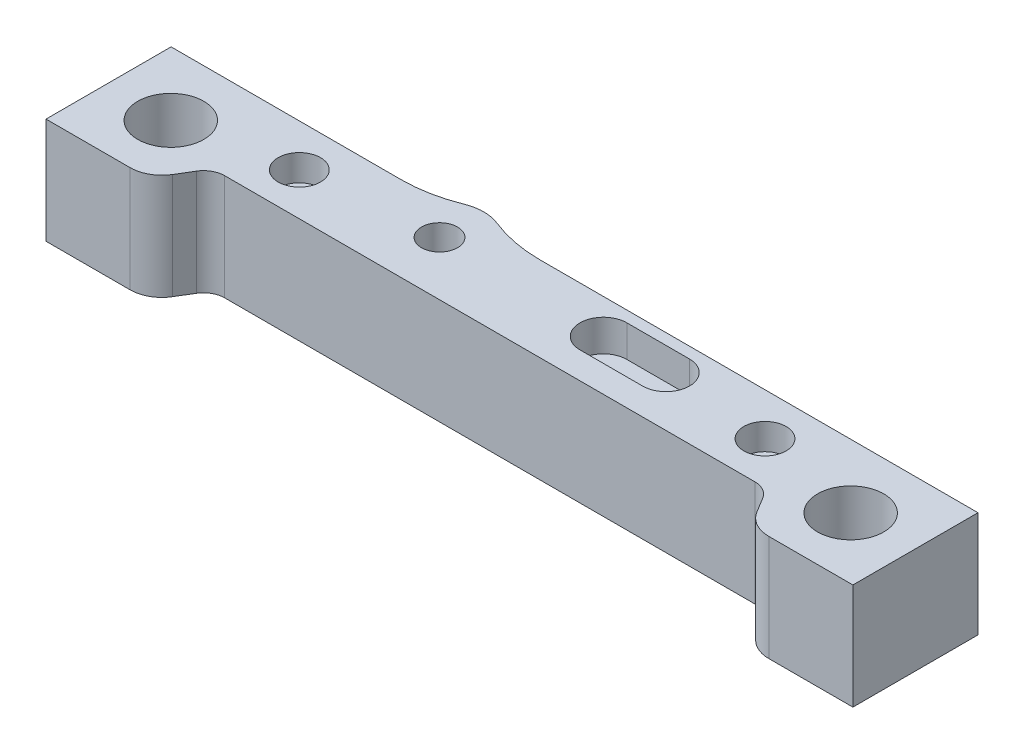
from build123d import *

# Parameters (mm, degrees)
SKETCH1_R           = 2
SKETCH1_R_2         = 3.125
SKETCH1_R_3         = 1.7
BOSS_EXTRUDE1_DEPTH = 10
FILLET2_R           = 3
FILLET1_R           = 2
SKETCH1_4_R         = 3.125
CUT_EXTRUDE3_DEPTH  = 5.07
SKETCH1_7_R         = 1.7
CUT_EXTRUDE6_DEPTH  = 10
CUT_EXTRUDE5_DEPTH  = 3
SKETCH1_5_R         = 2
CUT_EXTRUDE4_DEPTH  = 2.48
SKETCH4_R           = 1.5
CUT_EXTRUDE7_DEPTH  = 10
SKETCH5_R           = 2.725
CUT_EXTRUDE8_DEPTH  = 2.8


with BuildPart() as part:
    # Sketch1 → Boss-Extrude1 (new body)
    with BuildSketch(Plane(origin=(0, 0, 0), x_dir=(1, 0, 0), z_dir=(0, 1, 0))):
        with BuildLine():
            ThreePointArc((-11.409245094, 8.977987014), (-9.849239736, 9.28), (-8.289234378, 8.977987014))
            ThreePointArc((-8.289234378, 8.977987014), (-5.835653376, 8.254222737), (-3.289234378, 8.01))
            Line((-3.289234378, 8.01), (38.12, 8.01))
            Line((38.12, 8.01), (38.12, -3.81))
            Line((38.12, -3.81), (28.478275237, -3.81))
            Line((28.478275237, -3.81), (26.178275237, 0))
            Line((26.178275237, 0), (-26.178275237, 0))
            Line((-26.178275237, 0), (-28.478275237, -3.81))
            Line((-28.478275237, -3.81), (-38.12, -3.81))
            Line((-38.12, -3.81), (-38.12, 8.01))
            Line((-38.12, 8.01), (-16.409245094, 8.01))
            ThreePointArc((-16.409245094, 8.01), (-13.862826096, 8.254222737), (-11.409245094, 8.977987014))
        make_face()
        with Locations((22, 4.005)):
            Circle(SKETCH1_R, mode=Mode.SUBTRACT)
        with Locations((-22, 4.005)):
            Circle(SKETCH1_R, mode=Mode.SUBTRACT)
        with Locations((-32.12, 1.98)):
            Circle(SKETCH1_R_2, mode=Mode.SUBTRACT)
        with Locations((32.12, 1.98)):
            Circle(SKETCH1_R_2, mode=Mode.SUBTRACT)
        with Locations((-9.849239736, 5.1)):
            Circle(SKETCH1_R_3, mode=Mode.SUBTRACT)
        with BuildLine():
            ThreePointArc((11.912105026, 2.53), (14.127105026, 4.745), (11.912105026, 6.96))
            Line((11.912105026, 6.96), (5.992105026, 6.96))
            ThreePointArc((5.992105026, 6.96), (3.777105026, 4.745), (5.992105026, 2.53))
            Line((5.992105026, 2.53), (11.912105026, 2.53))
        make_face(mode=Mode.SUBTRACT)
        with Locations((-22, 4.005)):
            Circle(SKETCH1_R)
        with Locations((-9.849239736, 5.1)):
            Circle(SKETCH1_R_3)
        with Locations((-32.12, 1.98)):
            Circle(SKETCH1_R_2)
        with BuildLine():
            Line((5.992105026, 2.53), (11.912105026, 2.53))
            ThreePointArc((11.912105026, 2.53), (14.127105026, 4.745), (11.912105026, 6.96))
            Line((11.912105026, 6.96), (5.992105026, 6.96))
            ThreePointArc((5.992105026, 6.96), (3.777105026, 4.745), (5.992105026, 2.53))
        make_face()
        with Locations((22, 4.005)):
            Circle(SKETCH1_R)
        with Locations((32.12, 1.98)):
            Circle(SKETCH1_R_2)
    extrude(amount=-BOSS_EXTRUDE1_DEPTH)

    # Fillet2
    fillet2_edges = [part.edges().sort_by_distance(p)[0] for p in [
        (28.478275237, -5, 3.81),
        (-28.478275237, -5, 3.81),
    ]]
    fillet(fillet2_edges, radius=FILLET2_R)

    # Fillet1
    fillet1_edges = [part.edges().sort_by_distance(p)[0] for p in [
        (26.178275237, -5, 0),
        (-26.178275237, -5, 0),
    ]]
    fillet(fillet1_edges, radius=FILLET1_R)

    # Sketch1_4 → Cut-Extrude3 (cut)
    with BuildSketch(Plane(origin=(0, 0, 0), x_dir=(1, 0, 0), z_dir=(0, 1, 0))):
        with Locations((32.12, 1.98)):
            Circle(SKETCH1_4_R)
        with Locations((-32.12, 1.98)):
            Circle(SKETCH1_4_R)
    extrude(amount=-CUT_EXTRUDE3_DEPTH, mode=Mode.SUBTRACT)

    # Sketch1_7 → Cut-Extrude6 (cut)
    with BuildSketch(Plane(origin=(0, 0, 0), x_dir=(1, 0, 0), z_dir=(0, 1, 0))):
        with Locations((-9.849239736, 5.1)):
            Circle(SKETCH1_7_R)
    extrude(amount=-CUT_EXTRUDE6_DEPTH, mode=Mode.SUBTRACT)

    # Sketch1_6 → Cut-Extrude5 (cut)
    with BuildSketch(Plane(origin=(0, 0, 0), x_dir=(1, 0, 0), z_dir=(0, 1, 0))):
        with BuildLine():
            Line((5.992105026, 2.53), (11.912105026, 2.53))
            ThreePointArc((11.912105026, 2.53), (14.127105026, 4.745), (11.912105026, 6.96))
            Line((11.912105026, 6.96), (5.992105026, 6.96))
            ThreePointArc((5.992105026, 6.96), (3.777105026, 4.745), (5.992105026, 2.53))
        make_face()
    extrude(amount=-CUT_EXTRUDE5_DEPTH, mode=Mode.SUBTRACT)

    # Sketch1_5 → Cut-Extrude4 (cut)
    with BuildSketch(Plane(origin=(0, 0, 0), x_dir=(1, 0, 0), z_dir=(0, 1, 0))):
        with Locations((-22, 4.005)):
            Circle(SKETCH1_5_R)
        with Locations((22, 4.005)):
            Circle(SKETCH1_5_R)
    extrude(amount=-CUT_EXTRUDE4_DEPTH, mode=Mode.SUBTRACT)

    # Sketch4 → Cut-Extrude7 (cut)
    with BuildSketch(Plane(origin=(0, 0, 0), x_dir=(1, 0, 0), z_dir=(0, 1, 0))):
        with Locations((-22, 4.005)):
            Circle(SKETCH4_R)
        with Locations((22, 4.005)):
            Circle(SKETCH4_R)
    extrude(amount=-CUT_EXTRUDE7_DEPTH, mode=Mode.SUBTRACT)

    # Sketch5 → Cut-Extrude8 (cut)
    with BuildSketch(Plane.XZ.offset(10)):
        with Locations((22, -4.005)):
            Circle(SKETCH5_R)
        with Locations((-22, -4.005)):
            Circle(SKETCH5_R)
    extrude(amount=-CUT_EXTRUDE8_DEPTH, mode=Mode.SUBTRACT)


solid = part.part
